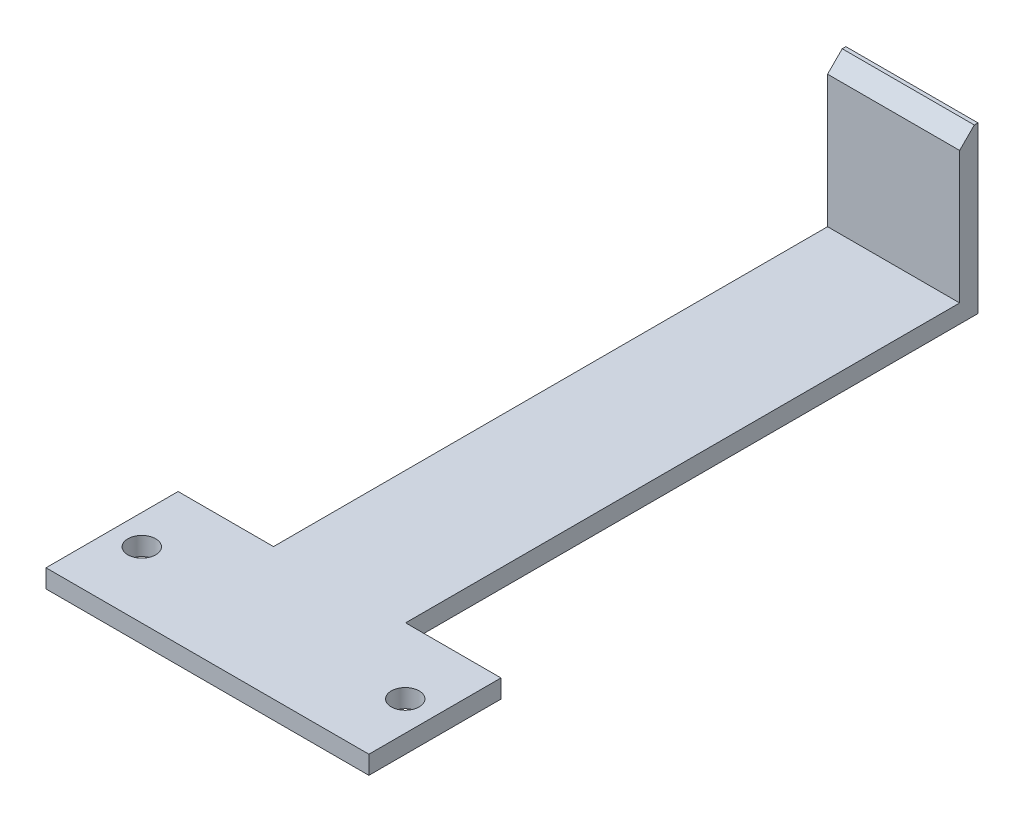
from build123d import *

# Parameters (mm, degrees)
SKETCH1_R           = 2.413
BOSS_EXTRUDE1_DEPTH = 3.175
SKETCH2_W           = 22.86
SKETCH2_H           = 3.175
BOSS_EXTRUDE2_DEPTH = 25.4
CHAMFER1_SIZE       = 2.54


with BuildPart() as part:
    # Sketch1 → Boss-Extrude1 (new body)
    with BuildSketch(Plane(origin=(0, 0, 0), x_dir=(1, 0, 0), z_dir=(0, 1, 0))):
        Polygon((-27.94, -11.43), (27.94, -11.43), (27.94, 11.43), (11.43, 11.43), (11.43, 110.49), (-11.43, 110.49), (-11.43, 11.43), (-27.94, 11.43), align=None)
        with Locations((-22.7965, 0)):
            Circle(SKETCH1_R, mode=Mode.SUBTRACT)
        with Locations((22.7965, 0)):
            Circle(SKETCH1_R, mode=Mode.SUBTRACT)
    extrude(amount=BOSS_EXTRUDE1_DEPTH)

    # Sketch2 → Boss-Extrude2 (add)
    with BuildSketch(Plane(origin=(0, 3.175, 0), x_dir=(1, 0, 0), z_dir=(0, 1, 0))):
        with Locations((0, 108.9025)):
            Rectangle(SKETCH2_W, SKETCH2_H)
    extrude(amount=BOSS_EXTRUDE2_DEPTH)

    # Chamfer1
    chamfer1_edges = [part.edges().sort_by_distance(p)[0] for p in [
        (0, 28.575, -107.315),
    ]]
    chamfer(chamfer1_edges, length=CHAMFER1_SIZE)


solid = part.part
